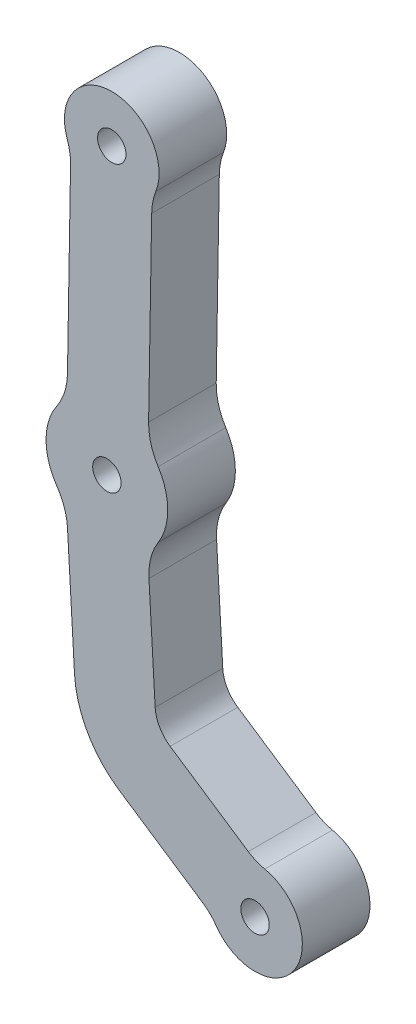
from build123d import *

# Parameters (mm, degrees)
CROQUIS1_R              = 2.1
SALIENTE_EXTRUIR1_DEPTH = 10


with BuildPart() as part:
    # Croquis1 → Saliente-Extruir1 (new body)
    with BuildSketch(Plane.XY):
        with BuildLine():
            Line((-38.297463257, 12.43995528), (-37.260227552, -5.729430968))
            ThreePointArc((-37.260227552, -5.729430968), (-35.302123155, -12.327326048), (-30.603607028, -17.356276091))
            Line((-30.603607028, -17.356276091), (-18.21840671, -25.610918133))
            ThreePointArc((-18.21840671, -25.610918133), (-17.187574321, -26.449545076), (-16.333802614, -27.467869404))
            ThreePointArc((-16.333802614, -27.467869404), (-4.742179488, -27.382198605), (-9.124005181, -16.65034556))
            ThreePointArc((-9.124005181, -16.65034556), (-10.39246616, -16.254217865), (-11.563209017, -15.625511598))
            Line((-11.563209017, -15.625511598), (-23.117754007, -7.92449503))
            ThreePointArc((-23.117754007, -7.92449503), (-24.683926049, -6.248178349), (-25.336627514, -4.048879989))
            Line((-25.336627514, -4.048879989), (-26.253353052, 12.009514726))
            ThreePointArc((-26.253353052, 12.009514726), (-25.979466195, 14.783004808), (-24.870216746, 17.339726714))
            ThreePointArc((-24.870216746, 17.339726714), (-23.472468719, 22.17483806), (-24.889381967, 27.004367864))
            ThreePointArc((-24.889381967, 27.004367864), (-25.965866103, 29.399778244), (-26.305025758, 32.003963281))
            Line((-26.305025758, 32.003963281), (-25.84900792, 58.962467928))
            ThreePointArc((-25.84900792, 58.962467928), (-25.680378416, 60.550833412), (-25.233618645, 62.084373932))
            ThreePointArc((-25.233618645, 62.084373932), (-31.635589461, 71.629913394), (-38.356741428, 62.306358804))
            ThreePointArc((-38.356741428, 62.306358804), (-37.962103741, 60.758585549), (-37.847291474, 59.165425451))
            Line((-37.847291474, 59.165425451), (-38.303309312, 32.206920805))
            ThreePointArc((-38.303309312, 32.206920805), (-38.73035213, 29.615696581), (-39.887236501, 27.25806491))
            ThreePointArc((-39.887236501, 27.25806491), (-41.472447055, 22.148538835), (-39.877642432, 17.041999163))
            ThreePointArc((-39.877642432, 17.041999163), (-38.770646544, 14.849791642), (-38.297463257, 12.43995528))
        make_face()
        with Locations((-10.567, -23.5)):
            Circle(CROQUIS1_R, mode=Mode.SUBTRACT)
        with Locations((-32.472451023, 22.156990874)):
            Circle(CROQUIS1_R, mode=Mode.SUBTRACT)
        with Locations((-31.753981392, 64.630914655)):
            Circle(CROQUIS1_R, mode=Mode.SUBTRACT)
    extrude(amount=SALIENTE_EXTRUIR1_DEPTH)


solid = part.part
